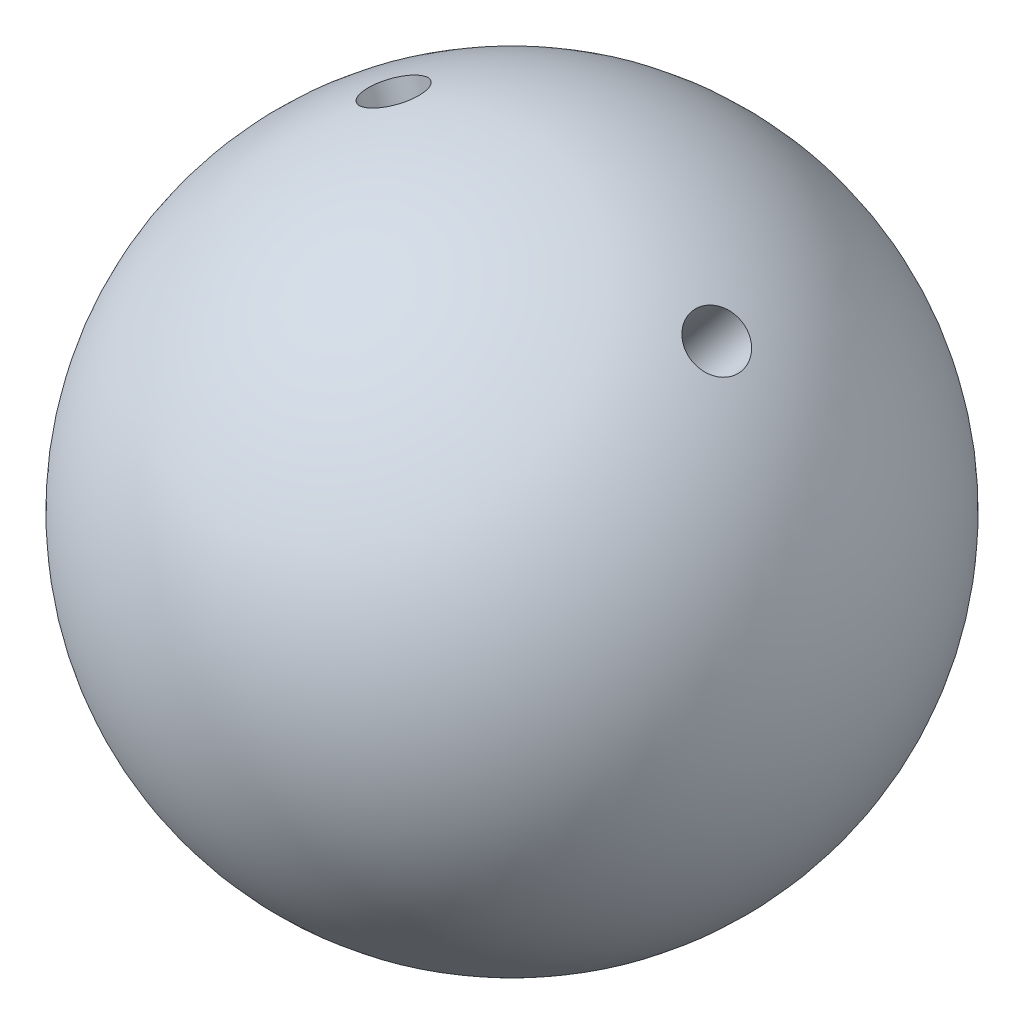
from build123d import *

# Parameters (mm, degrees)
F_10_0_10_DURCHMESSER_BOHRUNG1_D                     = 10
F_10_0_10_DURCHMESSER_BOHRUNG1_DEPTH                 = 22.64
F_10_0_10_DURCHMESSER_BOHRUNG1_CSINK_D               = 10.05
F_10_0_10_DURCHMESSER_BOHRUNG1_CSINK_ANGLE           = 90
F_10_0_10_DURCHMESSER_BOHRUNG1_TIP                   = 3.004303095
F_10_0_10_DURCHMESSER_BOHRUNG1_ON_FACE_2_D           = 10
F_10_0_10_DURCHMESSER_BOHRUNG1_ON_FACE_2_DEPTH       = 22.64
F_10_0_10_DURCHMESSER_BOHRUNG1_ON_FACE_2_CSINK_D     = 10.05
F_10_0_10_DURCHMESSER_BOHRUNG1_ON_FACE_2_CSINK_ANGLE = 90
F_10_0_10_DURCHMESSER_BOHRUNG1_ON_FACE_2_TIP         = 3.004303095
F_10_0_10_DURCHMESSER_BOHRUNG1_ON_FACE_3_D           = 10
F_10_0_10_DURCHMESSER_BOHRUNG1_ON_FACE_3_DEPTH       = 22.64
F_10_0_10_DURCHMESSER_BOHRUNG1_ON_FACE_3_CSINK_D     = 10.05
F_10_0_10_DURCHMESSER_BOHRUNG1_ON_FACE_3_CSINK_ANGLE = 90
F_10_0_10_DURCHMESSER_BOHRUNG1_ON_FACE_3_TIP         = 3.004303095


with BuildPart() as part:
    # Skizze1 → Rotation1 (revolve)
    with BuildSketch(Plane.XY):
        with BuildLine():
            Line((0, 60), (0, -60))
            ThreePointArc((0, -60), (60, 0), (0, 60))
        make_face()
    revolve(axis=Axis((0, 60, 0), (0, -1, 0)))

    # 10.0 _10_ Durchmesser Bohrung1
    with Locations(Plane(origin=(38.060989939, 46.377923621, 0.670257752), x_dir=(0.773013628, -0.634389416, 0), z_dir=(0.634349832, 0.772965394, 0.011170963))):
        with Locations((0, 0)):
            CounterSinkHole(F_10_0_10_DURCHMESSER_BOHRUNG1_D / 2, F_10_0_10_DURCHMESSER_BOHRUNG1_CSINK_D / 2, depth=F_10_0_10_DURCHMESSER_BOHRUNG1_DEPTH, counter_sink_angle=F_10_0_10_DURCHMESSER_BOHRUNG1_CSINK_ANGLE)
            with Locations((0, 0, -(F_10_0_10_DURCHMESSER_BOHRUNG1_DEPTH + F_10_0_10_DURCHMESSER_BOHRUNG1_TIP / 2))):  # 118° drill point
                Cone(0, F_10_0_10_DURCHMESSER_BOHRUNG1_D / 2, F_10_0_10_DURCHMESSER_BOHRUNG1_TIP, mode=Mode.SUBTRACT)

    # 10.0 _10_ Durchmesser Bohrung1 on face 2
    with Locations(Plane(origin=(-21.137326584, 56.151455854, 0.476896544), x_dir=(0.935887137, 0.352299968, 0), z_dir=(-0.35228884, 0.935857576, 0.007947996))):
        with Locations((0, 0)):
            CounterSinkHole(F_10_0_10_DURCHMESSER_BOHRUNG1_ON_FACE_2_D / 2, F_10_0_10_DURCHMESSER_BOHRUNG1_ON_FACE_2_CSINK_D / 2, depth=F_10_0_10_DURCHMESSER_BOHRUNG1_ON_FACE_2_DEPTH, counter_sink_angle=F_10_0_10_DURCHMESSER_BOHRUNG1_ON_FACE_2_CSINK_ANGLE)
            with Locations((0, 0, -(F_10_0_10_DURCHMESSER_BOHRUNG1_ON_FACE_2_DEPTH + F_10_0_10_DURCHMESSER_BOHRUNG1_ON_FACE_2_TIP / 2))):  # 118° drill point
                Cone(0, F_10_0_10_DURCHMESSER_BOHRUNG1_ON_FACE_2_D / 2, F_10_0_10_DURCHMESSER_BOHRUNG1_ON_FACE_2_TIP, mode=Mode.SUBTRACT)

    # 10.0 _10_ Durchmesser Bohrung1 on face 3
    with Locations(Plane(origin=(5.885070461, 34.684297812, -48.604170922), x_dir=(0, -0.813994513, -0.580872562), z_dir=(0.098084936, 0.578071622, -0.81006947))):
        with Locations((0, 0)):
            CounterSinkHole(F_10_0_10_DURCHMESSER_BOHRUNG1_ON_FACE_3_D / 2, F_10_0_10_DURCHMESSER_BOHRUNG1_ON_FACE_3_CSINK_D / 2, depth=F_10_0_10_DURCHMESSER_BOHRUNG1_ON_FACE_3_DEPTH, counter_sink_angle=F_10_0_10_DURCHMESSER_BOHRUNG1_ON_FACE_3_CSINK_ANGLE)
            with Locations((0, 0, -(F_10_0_10_DURCHMESSER_BOHRUNG1_ON_FACE_3_DEPTH + F_10_0_10_DURCHMESSER_BOHRUNG1_ON_FACE_3_TIP / 2))):  # 118° drill point
                Cone(0, F_10_0_10_DURCHMESSER_BOHRUNG1_ON_FACE_3_D / 2, F_10_0_10_DURCHMESSER_BOHRUNG1_ON_FACE_3_TIP, mode=Mode.SUBTRACT)


solid = part.part
